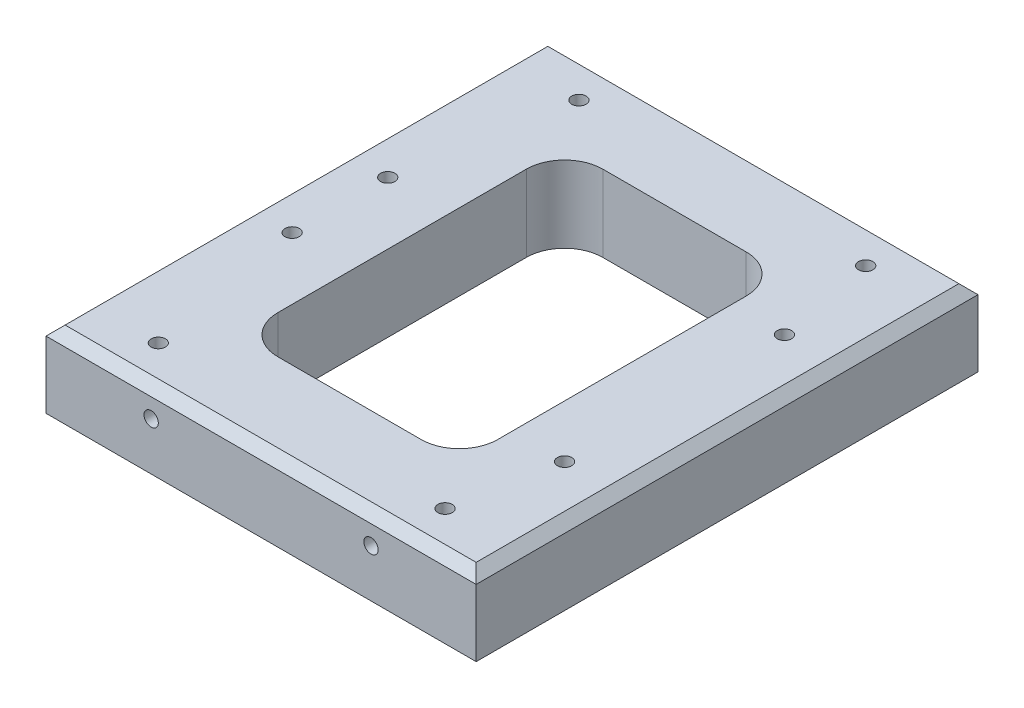
from build123d import *

# Parameters (mm, degrees)
SKETCH1_W           = 90
SKETCH1_H           = 105
SKETCH1_R           = 1.5
BOSS_EXTRUDE1_DEPTH = 16
CHAMFER1_SIZE       = 2
SKETCH2_R           = 1.5
CUT_EXTRUDE1_DEPTH  = 10


with BuildPart() as part:
    # Sketch1 → Boss-Extrude1 (new body)
    with BuildSketch(Plane(origin=(0, 0, 0), x_dir=(1, 0, 0), z_dir=(0, 1, 0))):
        Rectangle(SKETCH1_W, SKETCH1_H)
        with Locations((-30, 44)):
            Circle(SKETCH1_R, mode=Mode.SUBTRACT)
        with Locations((30, 44)):
            Circle(SKETCH1_R, mode=Mode.SUBTRACT)
        with Locations((30, -44)):
            Circle(SKETCH1_R, mode=Mode.SUBTRACT)
        with Locations((-30, -44)):
            Circle(SKETCH1_R, mode=Mode.SUBTRACT)
        with Locations((-36, -10)):
            Circle(SKETCH1_R, mode=Mode.SUBTRACT)
        with Locations((-36, 10)):
            Circle(SKETCH1_R, mode=Mode.SUBTRACT)
        with Locations((34, 23)):
            Circle(SKETCH1_R, mode=Mode.SUBTRACT)
        with Locations((34, -23)):
            Circle(SKETCH1_R, mode=Mode.SUBTRACT)
        with BuildLine():
            Line((-15, -34), (15, -34))
            ThreePointArc((15, -34), (20.656854249, -31.656854249), (23, -26))
            Line((23, -26), (23, 26))
            ThreePointArc((23, 26), (20.656854249, 31.656854249), (15, 34))
            Line((15, 34), (-15, 34))
            ThreePointArc((-15, 34), (-20.656854249, 31.656854249), (-23, 26))
            Line((-23, 26), (-23, -26))
            ThreePointArc((-23, -26), (-20.656854249, -31.656854249), (-15, -34))
        make_face(mode=Mode.SUBTRACT)
    extrude(amount=BOSS_EXTRUDE1_DEPTH)

    # Chamfer1
    chamfer1_edges = [part.edges().sort_by_distance(p)[0] for p in [
        (-45, 16, 0),
        (0, 16, 52.5),
        (45, 16, 0),
        (0, 16, -52.5),
    ]]
    chamfer(chamfer1_edges, length=CHAMFER1_SIZE)

    # Sketch2 → Cut-Extrude1 (cut)
    with BuildSketch(Plane.XY.offset(52.5)):
        with Locations((-23, 10)):
            Circle(SKETCH2_R)
        with Locations((23, 10)):
            Circle(SKETCH2_R)
    cut_extrude1 = extrude(amount=-CUT_EXTRUDE1_DEPTH, mode=Mode.SUBTRACT)

    # Mirror1: Cut-Extrude1 across plane
    add(cut_extrude1.mirror(Plane.XY), mode=Mode.SUBTRACT)


solid = part.part
